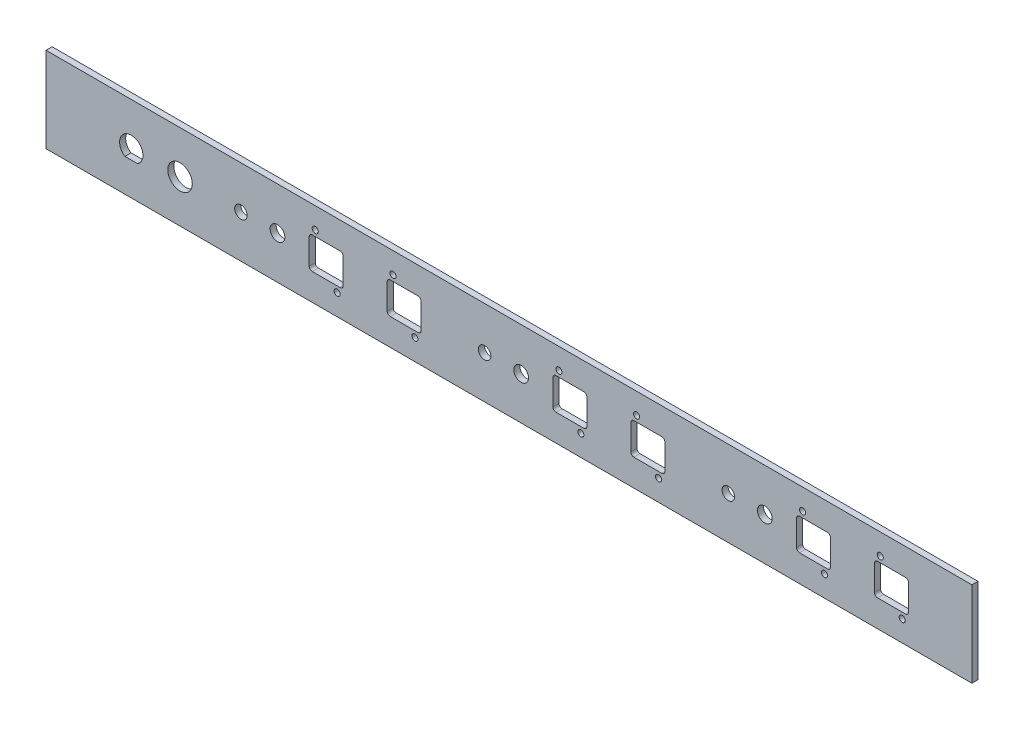
from build123d import *

# Parameters (mm, degrees)
SKETCH1_W              = 482.6
SKETCH1_H              = 44.45
BOSS_EXTRUDE1_DEPTH    = 3.175
SKETCH4_R              = 6.3881
CUT_EXTRUDE1_DEPTH     = 4.175
SKETCH3_R              = 3.85
SKETCH3_R_2            = 3.2512
SKETCH3_R_3            = 1.5875
SKETCH3_W              = 17.7292
SKETCH3_H              = 16.51
CUT_EXTRUDE2_DEPTH     = 4.175
FILLET1_R              = 1.6002
LPATTERN1_COUNT        = 3
LPATTERN1_PITCH        = 127
FILLET1_OF_LPATTERN1_R = 1.6002


with BuildPart() as part:
    # Sketch1 → Boss-Extrude1 (new body)
    with BuildSketch(Plane.XY):
        Rectangle(SKETCH1_W, SKETCH1_H)
    extrude(amount=BOSS_EXTRUDE1_DEPTH)

    # Sketch4 → Cut-Extrude1 (cut, through all)
    with BuildSketch(Plane.XY.offset(3.175)):
        with Locations((-171.45, 0)):
            Circle(SKETCH4_R)
        with BuildLine():
            Line((-200.181081932, -5.1054), (-193.518918068, -5.1054))
            ThreePointArc((-193.518918068, -5.1054), (-196.85, 6.096), (-200.181081932, -5.1054))
        make_face()
    extrude(amount=-CUT_EXTRUDE1_DEPTH, mode=Mode.SUBTRACT)

    # Sketch3 → Cut-Extrude2 (cut, through all)
    with BuildSketch(Plane.XY.offset(3.175)):
        with Locations((-120.65, 0)):
            Circle(SKETCH3_R)
        with Locations((-139.7, 0)):
            Circle(SKETCH3_R_2)
        with Locations((-100.965, 11.303)):
            Circle(SKETCH3_R_3)
        with Locations((-89.535, -11.303)):
            Circle(SKETCH3_R_3)
        with Locations((-60.452, 11.303)):
            Circle(SKETCH3_R_3)
        with Locations((-49.022, -11.303)):
            Circle(SKETCH3_R_3)
        with Locations((-95.25, 0)):
            Rectangle(SKETCH3_W, SKETCH3_H)
        with Locations((-54.61, 0)):
            Rectangle(SKETCH3_W, SKETCH3_H)
    cut_extrude2 = extrude(amount=-CUT_EXTRUDE2_DEPTH, mode=Mode.SUBTRACT)

    # Fillet1
    fillet1_edges = [part.edges().sort_by_distance(p)[0] for p in [
        (-45.7454, 8.255, 1.5875),
        (-45.7454, -8.255, 1.5875),
        (-63.4746, -8.255, 1.5875),
        (-63.4746, 8.255, 1.5875),
        (-86.3854, 8.255, 1.5875),
        (-86.3854, -8.255, 1.5875),
        (-104.1146, -8.255, 1.5875),
        (-104.1146, 8.255, 1.5875),
    ]]
    fillet(fillet1_edges, radius=FILLET1_R)

    # LPattern1: Cut-Extrude2 ×3
    with Locations(*[(i * LPATTERN1_PITCH, 0, 0) for i in range(1, LPATTERN1_COUNT)]):
        add(cut_extrude2, mode=Mode.SUBTRACT)

    # Fillet1 of LPattern1
    fillet1_of_lpattern1_edges = [part.edges().sort_by_distance(p)[0] for p in [
        (81.2546, 8.255, 1.5875),
        (81.2546, -8.255, 1.5875),
        (63.5254, -8.255, 1.5875),
        (63.5254, 8.255, 1.5875),
        (40.6146, 8.255, 1.5875),
        (40.6146, -8.255, 1.5875),
        (22.8854, -8.255, 1.5875),
        (22.8854, 8.255, 1.5875),
        (208.2546, 8.255, 1.5875),
        (208.2546, -8.255, 1.5875),
        (190.5254, -8.255, 1.5875),
        (190.5254, 8.255, 1.5875),
        (167.6146, 8.255, 1.5875),
        (167.6146, -8.255, 1.5875),
        (149.8854, -8.255, 1.5875),
        (149.8854, 8.255, 1.5875),
    ]]
    fillet(fillet1_of_lpattern1_edges, radius=FILLET1_OF_LPATTERN1_R)


solid = part.part
